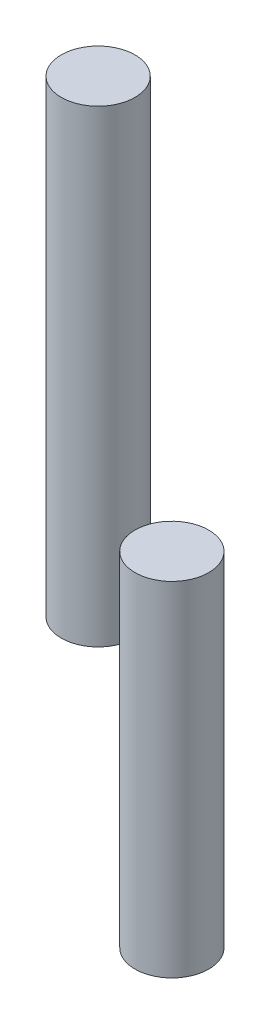
from build123d import *

# Parameters (mm, degrees)
SKETCH1_R                = 30
BOSS_EXTRUDE1_DEPTH      = 381
SKETCH2_R                = 30
BOSS_EXTRUDE2_DEPTH      = 203.2
BOSS_EXTRUDE2_DEPTH_BACK = 76.2


with BuildPart() as part:
    # Sketch1 → Boss-Extrude1 (new body)
    with BuildSketch(Plane(origin=(0, 0, 0), x_dir=(1, 0, 0), z_dir=(0, 1, 0))):
        Circle(SKETCH1_R)
    extrude(amount=BOSS_EXTRUDE1_DEPTH)


with BuildPart() as body_2:
    # Sketch2 → Boss-Extrude2 (new body, two sides)
    with BuildSketch(Plane.XZ) as boss_extrude2_sk:
        with Locations((60, 0)):
            Circle(SKETCH2_R)
    extrude(amount=BOSS_EXTRUDE2_DEPTH)
    extrude(boss_extrude2_sk.sketch, amount=-BOSS_EXTRUDE2_DEPTH_BACK)


solid = Compound([part.part, body_2.part])
